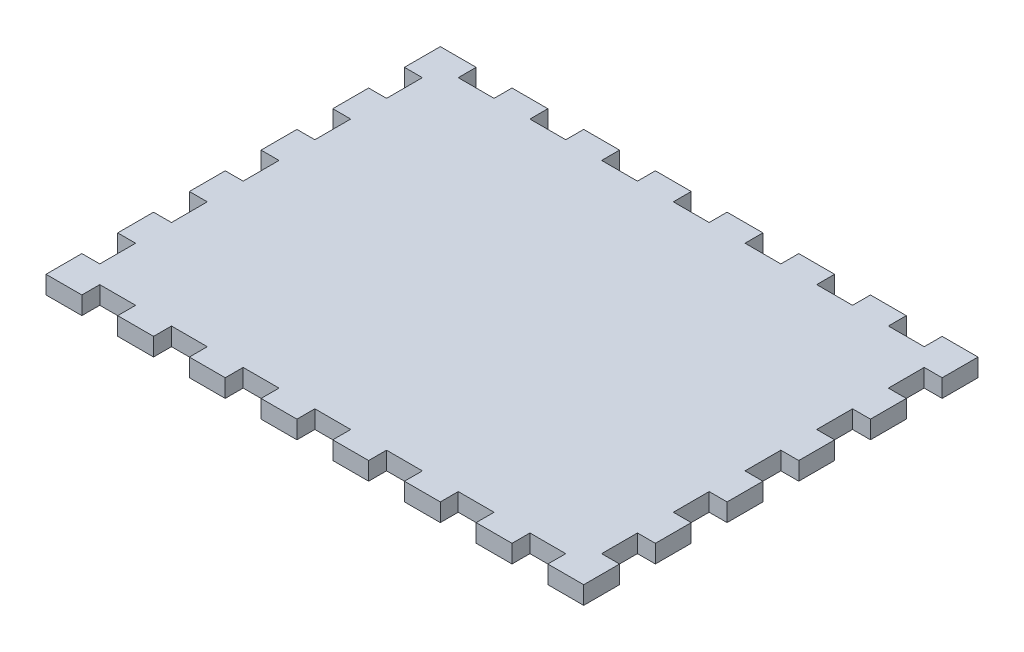
from build123d import *

# Parameters (mm, degrees)
SKETCH1_W                   = 190.5
SKETCH1_H                   = 139.7
BOSS_EXTRUDE1_DEPTH         = 6.35
CUT_EXTRUDE1_REACH          = 120.287
SKETCH2_W                   = 12.7
SKETCH2_H                   = 12.7
LPATTERN1_COUNT             = 4
LPATTERN1_PITCH             = 25.4
LPATTERN2_COUNT             = 4
LPATTERN2_PITCH             = 25.4
CIRPATTERN1_COUNT           = 2
CIRPATTERN1_COPY_1_REACH    = 120.287
CIRPATTERN1_COPY_1_SKETCH_W = 12.7
CIRPATTERN1_COPY_1_SKETCH_H = 12.7
CIRPATTERN1_COPY_2_REACH    = 120.287
CIRPATTERN1_COPY_2_SKETCH_W = 12.7
CIRPATTERN1_COPY_2_SKETCH_H = 12.7
CIRPATTERN1_COPY_3_REACH    = 120.287
CIRPATTERN1_COPY_3_SKETCH_W = 12.7
CIRPATTERN1_COPY_3_SKETCH_H = 12.7
CIRPATTERN1_COPY_4_REACH    = 120.287
CIRPATTERN1_COPY_4_SKETCH_W = 12.7
CIRPATTERN1_COPY_4_SKETCH_H = 12.7
CIRPATTERN1_COPY_5_REACH    = 120.287
CIRPATTERN1_COPY_5_SKETCH_W = 12.7
CIRPATTERN1_COPY_5_SKETCH_H = 12.7
CIRPATTERN1_COPY_6_REACH    = 120.287
CIRPATTERN1_COPY_6_SKETCH_W = 12.7
CIRPATTERN1_COPY_6_SKETCH_H = 12.7
CUT_EXTRUDE2_REACH          = 120.287
SKETCH3_W                   = 12.7
SKETCH3_H                   = 12.7
LPATTERN3_COUNT             = 3
LPATTERN3_PITCH             = 25.4
LPATTERN4_COUNT             = 3
LPATTERN4_PITCH             = 25.4
CIRPATTERN2_COUNT           = 2
CIRPATTERN2_COPY_1_REACH    = 120.287
CIRPATTERN2_COPY_1_SKETCH_W = 12.7
CIRPATTERN2_COPY_1_SKETCH_H = 12.7
CIRPATTERN2_COPY_2_REACH    = 120.287
CIRPATTERN2_COPY_2_SKETCH_W = 12.7
CIRPATTERN2_COPY_2_SKETCH_H = 12.7
CIRPATTERN2_COPY_3_REACH    = 120.287
CIRPATTERN2_COPY_3_SKETCH_W = 12.7
CIRPATTERN2_COPY_3_SKETCH_H = 12.7
CIRPATTERN2_COPY_4_REACH    = 120.287
CIRPATTERN2_COPY_4_SKETCH_W = 12.7
CIRPATTERN2_COPY_4_SKETCH_H = 12.7


with BuildPart() as part:
    # Sketch1 → Boss-Extrude1 (new body)
    with BuildSketch(Plane(origin=(0, 0, 0), x_dir=(1, 0, 0), z_dir=(0, 1, 0))):
        Rectangle(SKETCH1_W, SKETCH1_H)
    extrude(amount=BOSS_EXTRUDE1_DEPTH)

    # Sketch2 → Cut-Extrude1 (cut, up to next)
    with BuildSketch(Plane(origin=(0, 6.35, 0), x_dir=(1, 0, 0), z_dir=(0, 1, 0)), mode=Mode.PRIVATE) as cut_extrude1_sk1:
        with Locations((0, 69.85)):
            Rectangle(SKETCH2_W, SKETCH2_H)
    cut_extrude1_tool1 = extrude(cut_extrude1_sk1.sketch, amount=-CUT_EXTRUDE1_REACH, mode=Mode.PRIVATE) & part.part
    cut_extrude1 = cut_extrude1_tool1.solids().sort_by_distance((0, 6.35, -69.85))[0]
    add(cut_extrude1, mode=Mode.SUBTRACT)

    # LPattern1: Cut-Extrude1 ×4
    with Locations(*[(-i * LPATTERN1_PITCH, 0, 0) for i in range(1, LPATTERN1_COUNT)]):
        add(cut_extrude1, mode=Mode.SUBTRACT)

    # LPattern2: Cut-Extrude1 ×4
    with Locations(*[(i * LPATTERN2_PITCH, 0, 0) for i in range(1, LPATTERN2_COUNT)]):
        add(cut_extrude1, mode=Mode.SUBTRACT)

    # CirPattern1: Cut-Extrude1 ×2 about axis
    cirpattern1_axis = Axis((0, 0, 0), (0, 1, 0))
    for i in range(1, CIRPATTERN1_COUNT):
        add(cut_extrude1.rotate(cirpattern1_axis, i * 360 / CIRPATTERN1_COUNT), mode=Mode.SUBTRACT)

    # CirPattern1 copy 1 sketch → CirPattern1 copy 1 (cut, up to next)
    with BuildSketch(Plane(origin=(25.4, 6.35, 0), x_dir=(-1, 0, 0), z_dir=(0, 1, 0)), mode=Mode.PRIVATE) as cirpattern1_copy_1_sk1:
        with Locations((0, 69.85)):
            Rectangle(CIRPATTERN1_COPY_1_SKETCH_W, CIRPATTERN1_COPY_1_SKETCH_H)
    cirpattern1_copy_1_tool1 = extrude(cirpattern1_copy_1_sk1.sketch, amount=-CIRPATTERN1_COPY_1_REACH, mode=Mode.PRIVATE) & part.part
    add(cirpattern1_copy_1_tool1.solids().sort_by_distance((25.4, 6.35, 69.85))[0], mode=Mode.SUBTRACT)

    # CirPattern1 copy 2 sketch → CirPattern1 copy 2 (cut, up to next)
    with BuildSketch(Plane(origin=(50.8, 6.35, 0), x_dir=(-1, 0, 0), z_dir=(0, 1, 0)), mode=Mode.PRIVATE) as cirpattern1_copy_2_sk1:
        with Locations((0, 69.85)):
            Rectangle(CIRPATTERN1_COPY_2_SKETCH_W, CIRPATTERN1_COPY_2_SKETCH_H)
    cirpattern1_copy_2_tool1 = extrude(cirpattern1_copy_2_sk1.sketch, amount=-CIRPATTERN1_COPY_2_REACH, mode=Mode.PRIVATE) & part.part
    add(cirpattern1_copy_2_tool1.solids().sort_by_distance((50.8, 6.35, 69.85))[0], mode=Mode.SUBTRACT)

    # CirPattern1 copy 3 sketch → CirPattern1 copy 3 (cut, up to next)
    with BuildSketch(Plane(origin=(76.2, 6.35, 0), x_dir=(-1, 0, 0), z_dir=(0, 1, 0)), mode=Mode.PRIVATE) as cirpattern1_copy_3_sk1:
        with Locations((0, 69.85)):
            Rectangle(CIRPATTERN1_COPY_3_SKETCH_W, CIRPATTERN1_COPY_3_SKETCH_H)
    cirpattern1_copy_3_tool1 = extrude(cirpattern1_copy_3_sk1.sketch, amount=-CIRPATTERN1_COPY_3_REACH, mode=Mode.PRIVATE) & part.part
    add(cirpattern1_copy_3_tool1.solids().sort_by_distance((76.2, 6.35, 69.85))[0], mode=Mode.SUBTRACT)

    # CirPattern1 copy 4 sketch → CirPattern1 copy 4 (cut, up to next)
    with BuildSketch(Plane(origin=(-25.4, 6.35, 0), x_dir=(-1, 0, 0), z_dir=(0, 1, 0)), mode=Mode.PRIVATE) as cirpattern1_copy_4_sk1:
        with Locations((0, 69.85)):
            Rectangle(CIRPATTERN1_COPY_4_SKETCH_W, CIRPATTERN1_COPY_4_SKETCH_H)
    cirpattern1_copy_4_tool1 = extrude(cirpattern1_copy_4_sk1.sketch, amount=-CIRPATTERN1_COPY_4_REACH, mode=Mode.PRIVATE) & part.part
    add(cirpattern1_copy_4_tool1.solids().sort_by_distance((-25.4, 6.35, 69.85))[0], mode=Mode.SUBTRACT)

    # CirPattern1 copy 5 sketch → CirPattern1 copy 5 (cut, up to next)
    with BuildSketch(Plane(origin=(-50.8, 6.35, 0), x_dir=(-1, 0, 0), z_dir=(0, 1, 0)), mode=Mode.PRIVATE) as cirpattern1_copy_5_sk1:
        with Locations((0, 69.85)):
            Rectangle(CIRPATTERN1_COPY_5_SKETCH_W, CIRPATTERN1_COPY_5_SKETCH_H)
    cirpattern1_copy_5_tool1 = extrude(cirpattern1_copy_5_sk1.sketch, amount=-CIRPATTERN1_COPY_5_REACH, mode=Mode.PRIVATE) & part.part
    add(cirpattern1_copy_5_tool1.solids().sort_by_distance((-50.8, 6.35, 69.85))[0], mode=Mode.SUBTRACT)

    # CirPattern1 copy 6 sketch → CirPattern1 copy 6 (cut, up to next)
    with BuildSketch(Plane(origin=(-76.2, 6.35, 0), x_dir=(-1, 0, 0), z_dir=(0, 1, 0)), mode=Mode.PRIVATE) as cirpattern1_copy_6_sk1:
        with Locations((0, 69.85)):
            Rectangle(CIRPATTERN1_COPY_6_SKETCH_W, CIRPATTERN1_COPY_6_SKETCH_H)
    cirpattern1_copy_6_tool1 = extrude(cirpattern1_copy_6_sk1.sketch, amount=-CIRPATTERN1_COPY_6_REACH, mode=Mode.PRIVATE) & part.part
    add(cirpattern1_copy_6_tool1.solids().sort_by_distance((-76.2, 6.35, 69.85))[0], mode=Mode.SUBTRACT)

    # Sketch3 → Cut-Extrude2 (cut, up to next)
    with BuildSketch(Plane(origin=(0, 6.35, 0), x_dir=(1, 0, 0), z_dir=(0, 1, 0)), mode=Mode.PRIVATE) as cut_extrude2_sk1:
        with Locations((-95.25, 0)):
            Rectangle(SKETCH3_W, SKETCH3_H)
    cut_extrude2_tool1 = extrude(cut_extrude2_sk1.sketch, amount=-CUT_EXTRUDE2_REACH, mode=Mode.PRIVATE) & part.part
    cut_extrude2 = cut_extrude2_tool1.solids().sort_by_distance((-95.25, 6.35, 0))[0]
    add(cut_extrude2, mode=Mode.SUBTRACT)

    # LPattern3: Cut-Extrude2 ×3
    with Locations(*[(0, 0, -i * LPATTERN3_PITCH) for i in range(1, LPATTERN3_COUNT)]):
        add(cut_extrude2, mode=Mode.SUBTRACT)

    # LPattern4: Cut-Extrude2 ×3
    with Locations(*[(0, 0, i * LPATTERN4_PITCH) for i in range(1, LPATTERN4_COUNT)]):
        add(cut_extrude2, mode=Mode.SUBTRACT)

    # CirPattern2: Cut-Extrude2 ×2 about axis
    cirpattern2_axis = Axis((0, 0, 0), (0, 1, 0))
    for i in range(1, CIRPATTERN2_COUNT):
        add(cut_extrude2.rotate(cirpattern2_axis, i * 360 / CIRPATTERN2_COUNT), mode=Mode.SUBTRACT)

    # CirPattern2 copy 1 sketch → CirPattern2 copy 1 (cut, up to next)
    with BuildSketch(Plane(origin=(0, 6.35, 25.4), x_dir=(-1, 0, 0), z_dir=(0, 1, 0)), mode=Mode.PRIVATE) as cirpattern2_copy_1_sk1:
        with Locations((-95.25, 0)):
            Rectangle(CIRPATTERN2_COPY_1_SKETCH_W, CIRPATTERN2_COPY_1_SKETCH_H)
    cirpattern2_copy_1_tool1 = extrude(cirpattern2_copy_1_sk1.sketch, amount=-CIRPATTERN2_COPY_1_REACH, mode=Mode.PRIVATE) & part.part
    add(cirpattern2_copy_1_tool1.solids().sort_by_distance((95.25, 6.35, 25.4))[0], mode=Mode.SUBTRACT)

    # CirPattern2 copy 2 sketch → CirPattern2 copy 2 (cut, up to next)
    with BuildSketch(Plane(origin=(0, 6.35, 50.8), x_dir=(-1, 0, 0), z_dir=(0, 1, 0)), mode=Mode.PRIVATE) as cirpattern2_copy_2_sk1:
        with Locations((-95.25, 0)):
            Rectangle(CIRPATTERN2_COPY_2_SKETCH_W, CIRPATTERN2_COPY_2_SKETCH_H)
    cirpattern2_copy_2_tool1 = extrude(cirpattern2_copy_2_sk1.sketch, amount=-CIRPATTERN2_COPY_2_REACH, mode=Mode.PRIVATE) & part.part
    add(cirpattern2_copy_2_tool1.solids().sort_by_distance((95.25, 6.35, 50.8))[0], mode=Mode.SUBTRACT)

    # CirPattern2 copy 3 sketch → CirPattern2 copy 3 (cut, up to next)
    with BuildSketch(Plane(origin=(0, 6.35, -25.4), x_dir=(-1, 0, 0), z_dir=(0, 1, 0)), mode=Mode.PRIVATE) as cirpattern2_copy_3_sk1:
        with Locations((-95.25, 0)):
            Rectangle(CIRPATTERN2_COPY_3_SKETCH_W, CIRPATTERN2_COPY_3_SKETCH_H)
    cirpattern2_copy_3_tool1 = extrude(cirpattern2_copy_3_sk1.sketch, amount=-CIRPATTERN2_COPY_3_REACH, mode=Mode.PRIVATE) & part.part
    add(cirpattern2_copy_3_tool1.solids().sort_by_distance((95.25, 6.35, -25.4))[0], mode=Mode.SUBTRACT)

    # CirPattern2 copy 4 sketch → CirPattern2 copy 4 (cut, up to next)
    with BuildSketch(Plane(origin=(0, 6.35, -50.8), x_dir=(-1, 0, 0), z_dir=(0, 1, 0)), mode=Mode.PRIVATE) as cirpattern2_copy_4_sk1:
        with Locations((-95.25, 0)):
            Rectangle(CIRPATTERN2_COPY_4_SKETCH_W, CIRPATTERN2_COPY_4_SKETCH_H)
    cirpattern2_copy_4_tool1 = extrude(cirpattern2_copy_4_sk1.sketch, amount=-CIRPATTERN2_COPY_4_REACH, mode=Mode.PRIVATE) & part.part
    add(cirpattern2_copy_4_tool1.solids().sort_by_distance((95.25, 6.35, -50.8))[0], mode=Mode.SUBTRACT)


solid = part.part
